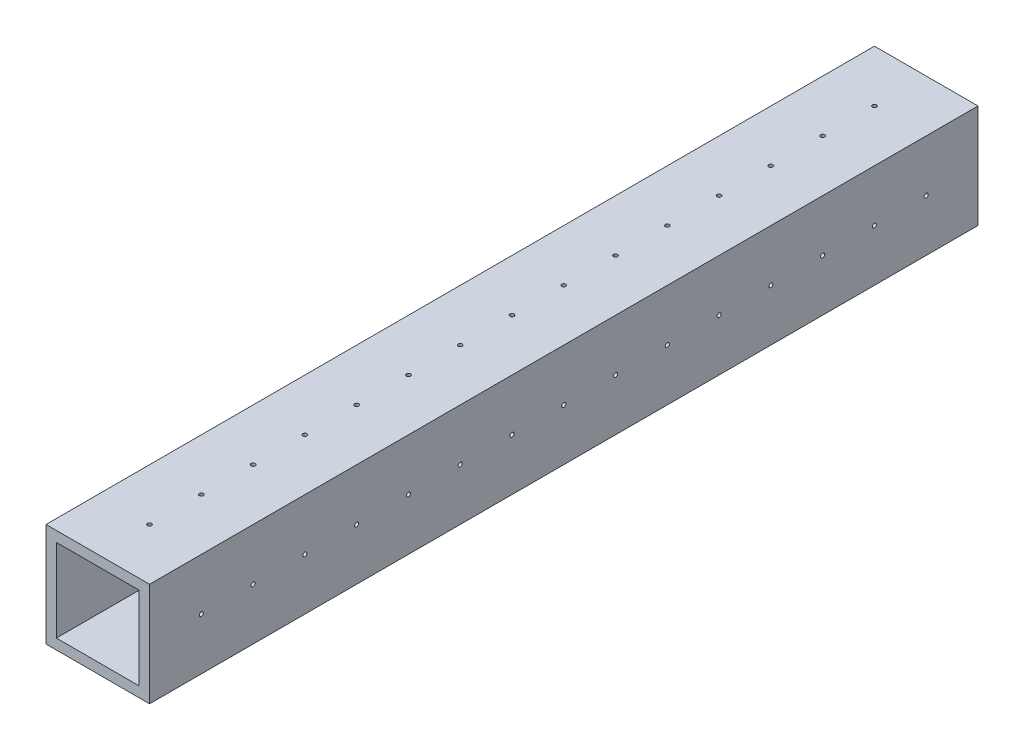
from build123d import *

# Parameters (mm, degrees)
SKETCH1_W               = 25.4
SKETCH1_H               = 25.4
SKETCH1_W_2             = 20.32
SKETCH1_H_2             = 20.32
BOSS_EXTRUDE1_DEPTH     = 203.2
SKETCH2_R               = 0.5
CUT_EXTRUDE1_DEPTH      = 1
CUT_EXTRUDE1_DEPTH_BACK = 26.4
SKETCH3_R               = 0.5
CUT_EXTRUDE2_DEPTH      = 1
CUT_EXTRUDE2_DEPTH_BACK = 26.4


with BuildPart() as part:
    # Sketch1 → Boss-Extrude1 (new body)
    with BuildSketch(Plane.XY):
        with Locations((6.158862876, -0.297324415)):
            Rectangle(SKETCH1_W, SKETCH1_H)
        with Locations((6.158862876, -0.297324415)):
            Rectangle(SKETCH1_W_2, SKETCH1_H_2, mode=Mode.SUBTRACT)
    extrude(amount=BOSS_EXTRUDE1_DEPTH)

    # Sketch2 → Cut-Extrude1 (cut, two sides)
    with BuildSketch(Plane(origin=(18.858862876, 0, 0), x_dir=(0, 0, -1), z_dir=(1, 0, 0))) as cut_extrude1_sk:
        with Locations((-190.5, -0.297324415)):
            Circle(SKETCH2_R)
        with Locations((-177.8, -0.297324415)):
            Circle(SKETCH2_R)
        with Locations((-165.1, -0.297324415)):
            Circle(SKETCH2_R)
        with Locations((-152.4, -0.297324415)):
            Circle(SKETCH2_R)
        with Locations((-139.7, -0.297324415)):
            Circle(SKETCH2_R)
        with Locations((-127, -0.297324415)):
            Circle(SKETCH2_R)
        with Locations((-114.3, -0.297324415)):
            Circle(SKETCH2_R)
        with Locations((-101.6, -0.297324415)):
            Circle(SKETCH2_R)
        with Locations((-88.9, -0.297324415)):
            Circle(SKETCH2_R)
        with Locations((-76.2, -0.297324415)):
            Circle(SKETCH2_R)
        with Locations((-63.5, -0.297324415)):
            Circle(SKETCH2_R)
        with Locations((-50.8, -0.297324415)):
            Circle(SKETCH2_R)
        with Locations((-38.1, -0.297324415)):
            Circle(SKETCH2_R)
        with Locations((-25.4, -0.297324415)):
            Circle(SKETCH2_R)
        with Locations((-12.7, -0.297324415)):
            Circle(SKETCH2_R)
    extrude(amount=CUT_EXTRUDE1_DEPTH, mode=Mode.SUBTRACT)
    extrude(cut_extrude1_sk.sketch, amount=-CUT_EXTRUDE1_DEPTH_BACK, mode=Mode.SUBTRACT)

    # Sketch3 → Cut-Extrude2 (cut, two sides)
    with BuildSketch(Plane(origin=(0, 12.402675585, 0), x_dir=(1, 0, 0), z_dir=(0, 1, 0))) as cut_extrude2_sk:
        with Locations((6.158862876, -190.5)):
            Circle(SKETCH3_R)
        with Locations((6.158862876, -177.8)):
            Circle(SKETCH3_R)
        with Locations((6.158862876, -165.1)):
            Circle(SKETCH3_R)
        with Locations((6.158862876, -152.4)):
            Circle(SKETCH3_R)
        with Locations((6.158862876, -139.7)):
            Circle(SKETCH3_R)
        with Locations((6.158862876, -127)):
            Circle(SKETCH3_R)
        with Locations((6.158862876, -114.3)):
            Circle(SKETCH3_R)
        with Locations((6.158862876, -101.6)):
            Circle(SKETCH3_R)
        with Locations((6.158862876, -88.9)):
            Circle(SKETCH3_R)
        with Locations((6.158862876, -76.2)):
            Circle(SKETCH3_R)
        with Locations((6.158862876, -63.5)):
            Circle(SKETCH3_R)
        with Locations((6.158862876, -50.8)):
            Circle(SKETCH3_R)
        with Locations((6.158862876, -38.1)):
            Circle(SKETCH3_R)
        with Locations((6.158862876, -25.4)):
            Circle(SKETCH3_R)
        with Locations((6.158862876, -12.7)):
            Circle(SKETCH3_R)
    extrude(amount=CUT_EXTRUDE2_DEPTH, mode=Mode.SUBTRACT)
    extrude(cut_extrude2_sk.sketch, amount=-CUT_EXTRUDE2_DEPTH_BACK, mode=Mode.SUBTRACT)


solid = part.part
